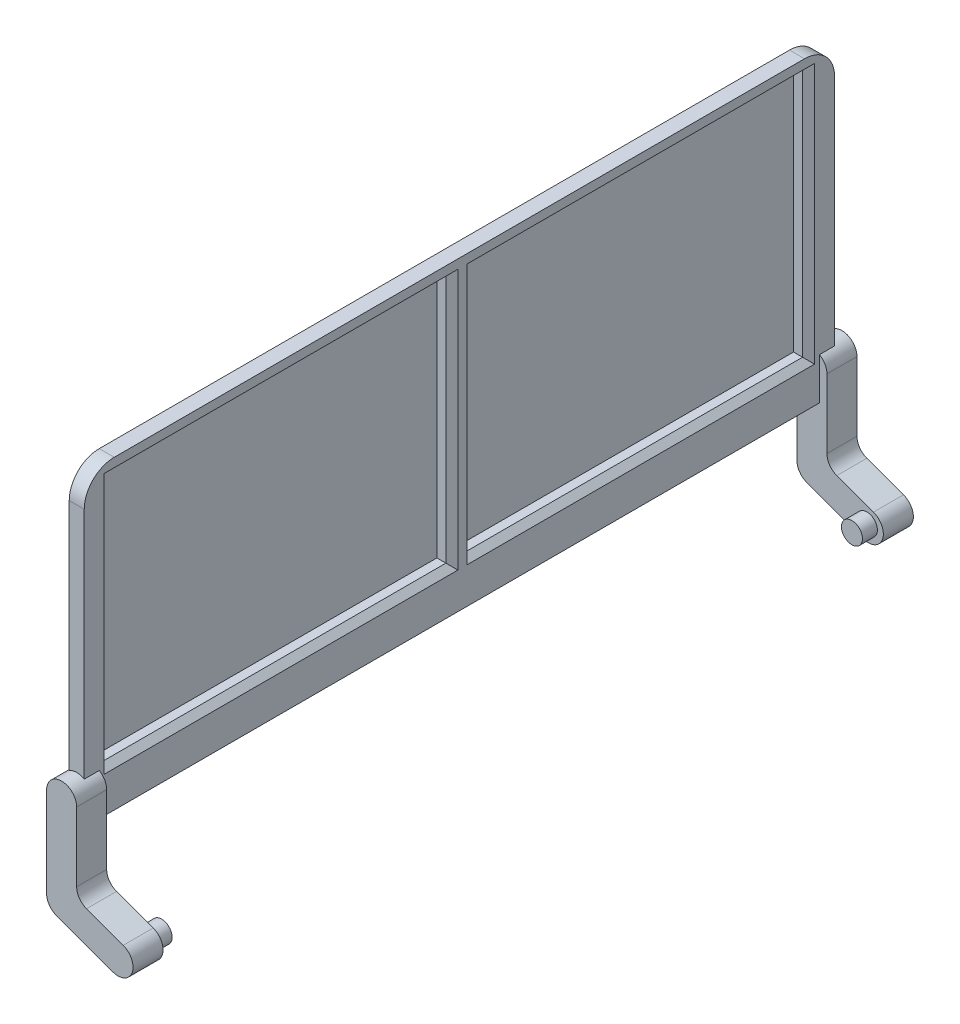
from build123d import *

# Parameters (mm, degrees)
SKETCH1_W             = 113.839745962
SKETCH1_H             = 82.8
BOSS_EXTRUDE1_DEPTH   = 5
CHAMFER1_SIZE         = 2
BOSS_EXTRUDE2_DEPTH   = 250
BOSS_EXTRUDE5_DEPTH   = 5
SKETCH4_R             = 3.5
BOSS_EXTRUDE6_DEPTH   = 5
SKETCH8_W             = 113.839745962
SKETCH8_H             = 82.8
BOSS_EXTRUDE8_DEPTH   = 1
BOSS_EXTRUDE8_2_DEPTH = 1


with BuildPart() as part:
    # Sketch1 → Boss-Extrude1 (new body)
    with BuildSketch(Plane(origin=(0, 0, 0), x_dir=(0, 0, -1), z_dir=(1, 0, 0))):
        with BuildLine():
            Line((-115, 101.8), (115, 101.8))
            ThreePointArc((115, 101.8), (122.071067812, 98.871067812), (125, 91.8))
            Line((125, 91.8), (125, 0))
            Line((125, 0), (-125, 0))
            Line((-125, 0), (-125, 91.8))
            ThreePointArc((-125, 91.8), (-122.071067812, 98.871067812), (-115, 101.8))
        make_face()
        with Locations((59.419872981, 55.4)):
            Rectangle(SKETCH1_W, SKETCH1_H, mode=Mode.SUBTRACT)
        with Locations((-59.419872981, 55.4)):
            Rectangle(SKETCH1_W, SKETCH1_H, mode=Mode.SUBTRACT)
    extrude(amount=BOSS_EXTRUDE1_DEPTH)

    # Chamfer1
    chamfer1_edges = [part.edges().sort_by_distance(p)[0] for p in [
        (5, 55.4, 116.339745962),
        (5, 14, 59.419872981),
        (5, 55.4, 2.5),
        (5, 96.8, 59.419872981),
        (5, 55.4, -116.339745962),
        (5, 96.8, -59.419872981),
        (5, 14, -59.419872981),
    ]]
    chamfer(chamfer1_edges, length=CHAMFER1_SIZE)

    # Sketch2 → Boss-Extrude2 (add, through all)
    with BuildSketch(Plane.XY.offset(125)):
        Polygon((0, 0), (5, 0), (0, 0.881634904), align=None)
    extrude(amount=-BOSS_EXTRUDE2_DEPTH)

    # Sketch3 → Boss-Extrude5 (add, symmetric)
    with BuildSketch(Plane.XY.offset(125)):
        with BuildLine():
            Line((-2.528093442, 9.6), (-2.528093442, -20.4))
            ThreePointArc((-2.528093442, -20.4), (-1.623853664, -23.267882182), (0.761805841, -25.098463104))
            Line((0.761805841, -25.098463104), (19.555658257, -31.93886597))
            ThreePointArc((19.555658257, -31.93886597), (25.964222077, -28.950503583), (22.97585969, -22.541939763))
            Line((22.97585969, -22.541939763), (10.761805841, -18.096387722))
            ThreePointArc((10.761805841, -18.096387722), (8.376146336, -16.2658068), (7.471906558, -13.397924618))
            Line((7.471906558, -13.397924618), (7.471906558, 9.6))
            ThreePointArc((7.471906558, 9.6), (2.471906558, 14.6), (-2.528093442, 9.6))
        make_face()
    boss_extrude5 = extrude(amount=BOSS_EXTRUDE5_DEPTH, both=True)

    # Sketch4 → Boss-Extrude6 (add)
    with BuildSketch(Plane(origin=(0, 0, 120), x_dir=(-1, 0, 0), z_dir=(0, 0, -1))):
        with Locations((-20.795912663, -27.069392795)):
            Circle(SKETCH4_R)
    boss_extrude6 = extrude(amount=BOSS_EXTRUDE6_DEPTH)

    # Mirror13: Boss-Extrude5, Boss-Extrude6 across plane
    add(boss_extrude5.mirror(Plane.XY))
    add(boss_extrude6.mirror(Plane.XY))


with BuildPart() as body_2:
    # Sketch8 → Boss-Extrude8 (new body)
    with BuildSketch(Plane.ZY):
        with Locations((59.419872981, 55.4)):
            Rectangle(SKETCH8_W, SKETCH8_H)
    extrude(amount=BOSS_EXTRUDE8_DEPTH)


with BuildPart() as body_3:
    # Sketch8 → Boss-Extrude8 2 (new body)
    with BuildSketch(Plane.ZY):
        with Locations((-59.419872981, 55.4)):
            Rectangle(SKETCH8_W, SKETCH8_H)
    extrude(amount=BOSS_EXTRUDE8_2_DEPTH)


solid = Compound([part.part, body_2.part, body_3.part])
